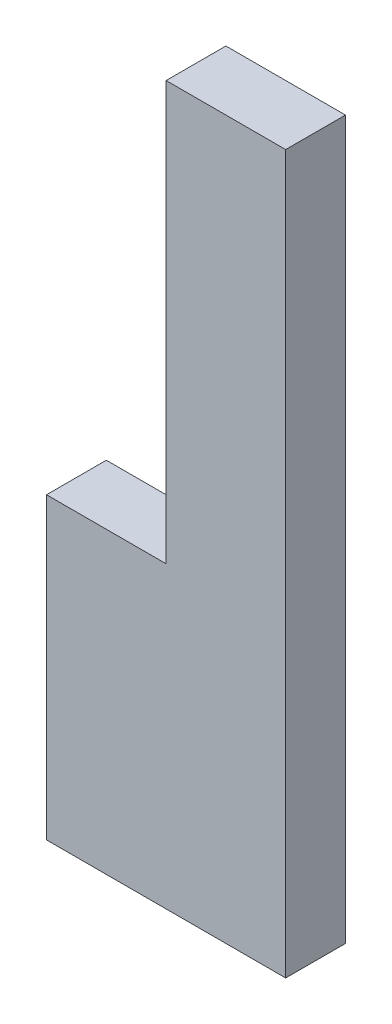
from build123d import *

# Parameters (mm, degrees)
EXTRUSION1_DEPTH = 1


with BuildPart() as part:
    # Esquisse1 → Extrusion1 (new body)
    with BuildSketch(Plane.XY):
        Polygon((0, 0), (0, 12), (-2, 12), (-2, 5), (-4, 5), (-4, 0), align=None)
    extrude(amount=EXTRUSION1_DEPTH)


solid = part.part
